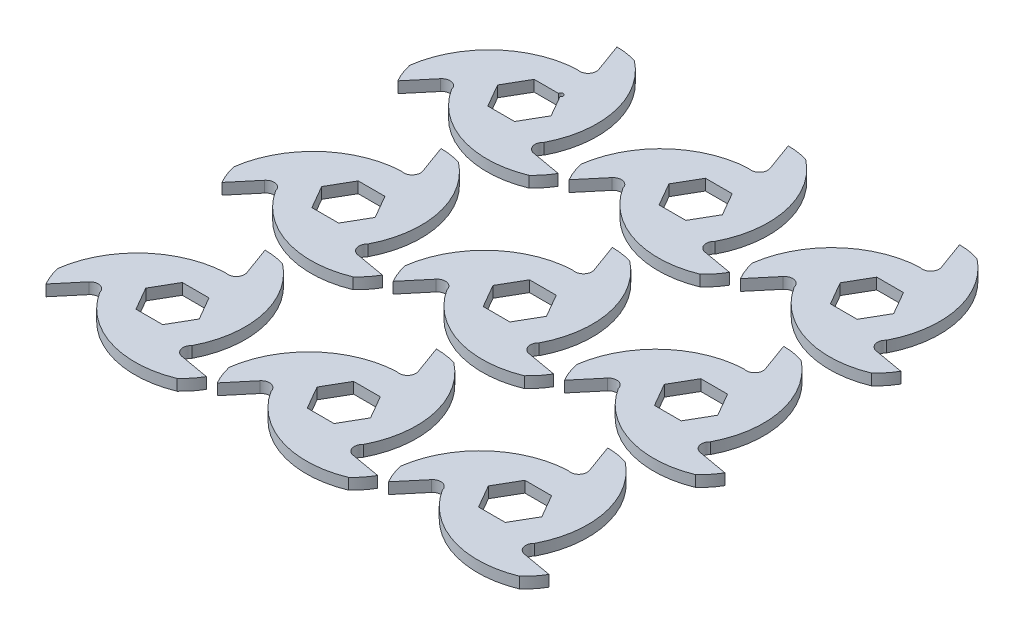
from build123d import *

# Parameters (mm, degrees)
BOSS_EXTRUDE2_DEPTH = 3.048
CUT_EXTRUDE1_DEPTH  = 7.096
LPATTERN1_COUNT     = 3
LPATTERN1_PITCH     = 96.52
LPATTERN1_2_COUNT   = 3
LPATTERN1_2_PITCH   = 93.98
SKETCH4_R           = 1.27
CUT_EXTRUDE2_DEPTH  = 7.096


with BuildPart() as part:
    # Sketch2 → Boss-Extrude2 (new body, symmetric)
    with BuildSketch(Plane(origin=(0, 0, 0), x_dir=(1, 0, 0), z_dir=(0, 1, 0))):
        with BuildLine():
            Line((0, 50.8), (5.699182497, 35.141624781))
            ThreePointArc((5.699182497, 35.141624781), (4.697625818, 30.400196659), (0, 29.21))
            ThreePointArc((0, 29.21), (-40.712457699, 16.982230342), (-43.994090512, -25.4))
            Line((-43.994090512, -25.4), (-33.283131039, -12.635175567))
            ThreePointArc((-33.283131039, -12.635175567), (-28.676155496, -11.131835033), (-25.296602045, -14.605))
            ThreePointArc((-25.296602045, -14.605), (5.64918596, -43.749137789), (43.994090512, -25.4))
            Line((43.994090512, -25.4), (27.583948542, -22.506449213))
            ThreePointArc((27.583948542, -22.506449213), (23.978529677, -19.268361626), (25.296602045, -14.605))
            ThreePointArc((25.296602045, -14.605), (35.063271738, 26.766907447), (0, 50.8))
        make_face()
        Polygon((7.332348419, 12.7), (14.664696837, 0), (7.332348419, -12.7), (-7.332348419, -12.7), (-14.664696837, 0), (-7.332348419, 12.7), align=None, mode=Mode.SUBTRACT)
    extrude(amount=BOSS_EXTRUDE2_DEPTH, both=True)

    # Sketch3 → Cut-Extrude1 (cut, through all)
    with BuildSketch(Plane(origin=(0, 3.048, 0), x_dir=(1, 0, 0), z_dir=(0, 1, 0))):
        with BuildLine():
            ThreePointArc((0, 29.21), (-36.786884898, 21.158593478), (-48.137903328, -14.747595795))
            ThreePointArc((-48.137903328, -14.747595795), (-32.049598102, 15.970797155), (0, 29.21))
        make_face()
        with BuildLine():
            ThreePointArc((11.297159061, 49.062445064), (29.855915106, 19.77036756), (25.296602045, -14.605))
            ThreePointArc((25.296602045, -14.605), (36.717321909, 21.279080109), (11.297159061, 49.062445064))
        make_face()
        with BuildLine():
            ThreePointArc((-25.296602045, -14.605), (0.069562989, -42.437673587), (36.840744267, -34.314849269))
            ThreePointArc((36.840744267, -34.314849269), (2.193682996, -35.741164715), (-25.296602045, -14.605))
        make_face()
    extrude(amount=-CUT_EXTRUDE1_DEPTH, mode=Mode.SUBTRACT)


with BuildPart() as lpattern1_1:
    # LPattern1: pattern copy
    add(part.part.moved(Location(Vector(0, 0, 1) * (1 * LPATTERN1_PITCH))))


with BuildPart() as lpattern1_2:
    # LPattern1: pattern copy
    add(part.part.moved(Location(Vector(0, 0, 1) * (2 * LPATTERN1_PITCH))))


with BuildPart() as lpattern1_2_1:
    # LPattern1 2: pattern copy
    add(part.part.moved(Location(Vector(1, 0, 0) * (1 * LPATTERN1_2_PITCH))))


with BuildPart() as lpattern1_2_2:
    # LPattern1 2: pattern copy
    add(part.part.moved(Location(Vector(1, 0, 0) * (2 * LPATTERN1_2_PITCH))))


with BuildPart() as lpattern1_2_3:
    # LPattern1 2: pattern copy
    add(lpattern1_1.part.moved(Location(Vector(1, 0, 0) * (1 * LPATTERN1_2_PITCH))))


with BuildPart() as lpattern1_2_4:
    # LPattern1 2: pattern copy
    add(lpattern1_1.part.moved(Location(Vector(1, 0, 0) * (2 * LPATTERN1_2_PITCH))))


with BuildPart() as lpattern1_2_5:
    # LPattern1 2: pattern copy
    add(lpattern1_2.part.moved(Location(Vector(1, 0, 0) * (1 * LPATTERN1_2_PITCH))))


with BuildPart() as lpattern1_2_6:
    # LPattern1 2: pattern copy
    add(lpattern1_2.part.moved(Location(Vector(1, 0, 0) * (2 * LPATTERN1_2_PITCH))))


with BuildPart() as part_1:
    add(part.part)

    # Sketch4 → Cut-Extrude2 (cut, through all)
    with BuildSketch(Plane(origin=(0, 3.048, 0), x_dir=(1, 0, 0), z_dir=(0, 1, 0))):
        with Locations((7.332348419, 12.7)):
            Circle(SKETCH4_R)
    extrude(amount=-CUT_EXTRUDE2_DEPTH, mode=Mode.SUBTRACT)


solid = Compound([lpattern1_1.part, lpattern1_2.part, lpattern1_2_1.part, lpattern1_2_2.part, lpattern1_2_3.part, lpattern1_2_4.part, lpattern1_2_5.part, lpattern1_2_6.part, part_1.part])
